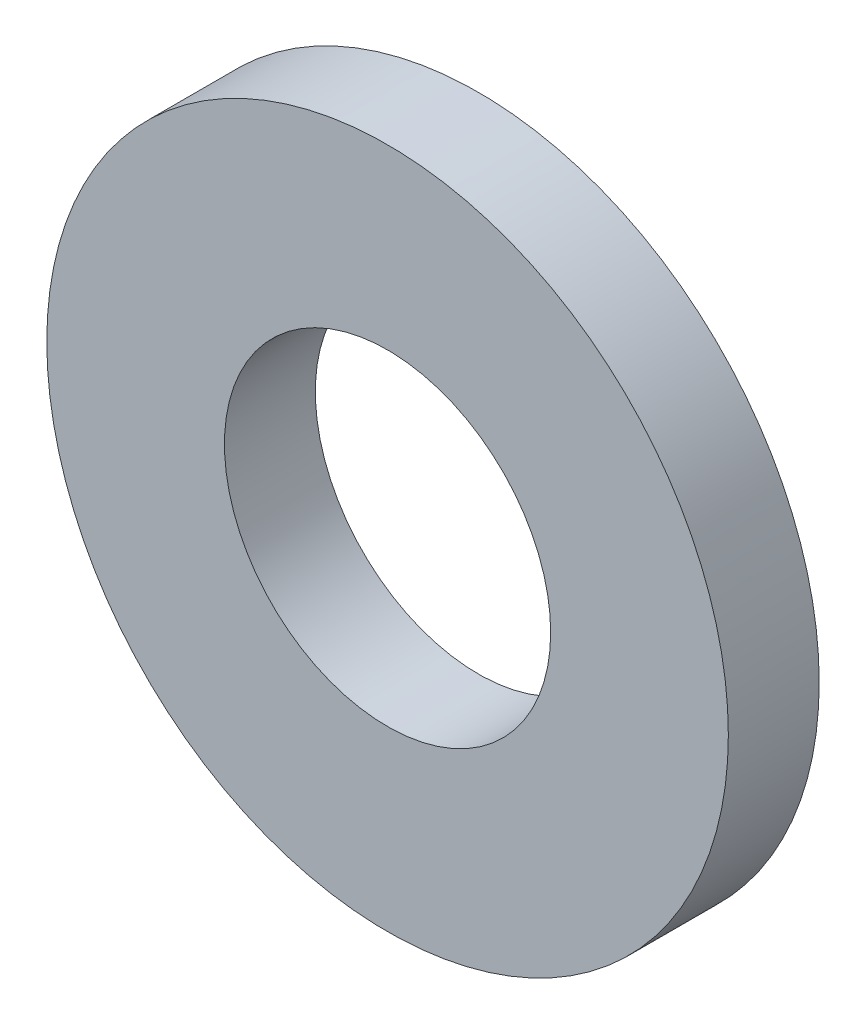
from build123d import *

# Parameters (mm, degrees)
ESQUISSE1_R        = 7.5
ESQUISSE1_R_2      = 3.59
BOSS_EXTRU_1_DEPTH = 2


with BuildPart() as part:
    # Esquisse1 → Boss.-Extru.1 (new body)
    with BuildSketch(Plane.XY):
        Circle(ESQUISSE1_R)
        Circle(ESQUISSE1_R_2, mode=Mode.SUBTRACT)
    extrude(amount=BOSS_EXTRU_1_DEPTH)


solid = part.part
